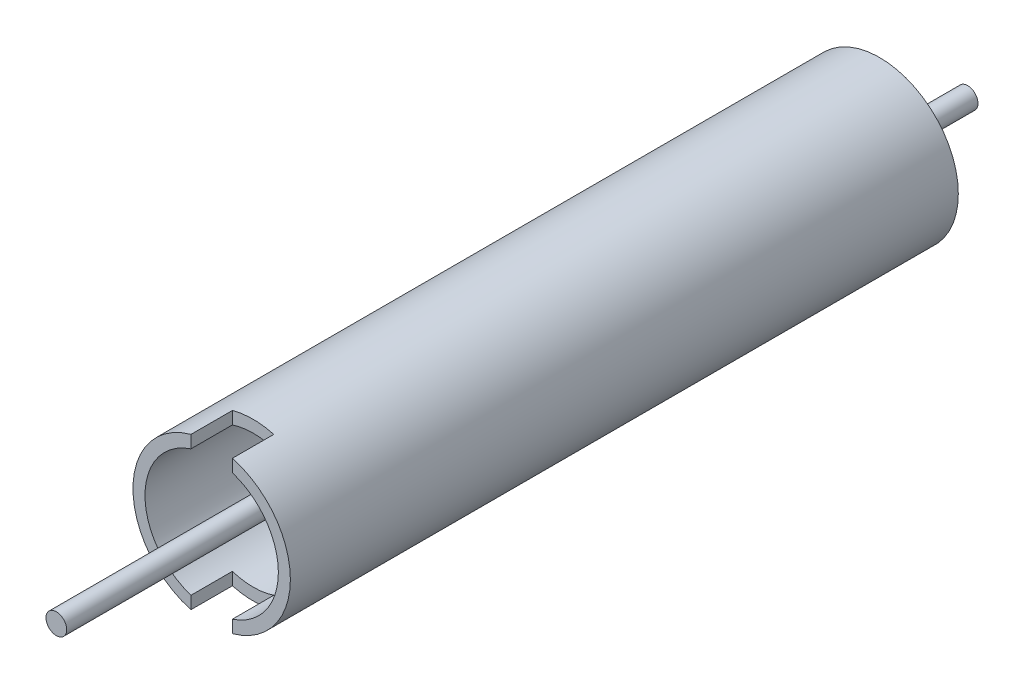
from build123d import *

# Parameters (mm, degrees)
SKETCH1_R                = 3.175
BOSS_EXTRUDE1_DEPTH      = 139.7
SKETCH2_R                = 24.13
SKETCH2_R_2              = 20.447
BOSS_EXTRUDE2_DEPTH      = 92.075
BOSS_EXTRUDE2_DEPTH_BACK = 112.7125
CUT_EXTRUDE1_START       = 19.43598
SKETCH3_W                = 12.7
SKETCH3_H                = 12.7
CUT_EXTRUDE1_DEPTH       = 4.69402


with BuildPart() as part:
    # Sketch1 → Boss-Extrude1 (new body, symmetric)
    with BuildSketch(Plane.XY):
        Circle(SKETCH1_R)
    extrude(amount=BOSS_EXTRUDE1_DEPTH, both=True)


with BuildPart() as body_2:
    # Sketch2 → Boss-Extrude2 (new body, two sides)
    with BuildSketch(Plane.XY) as boss_extrude2_sk:
        Circle(SKETCH2_R)
        Circle(SKETCH2_R_2, mode=Mode.SUBTRACT)
    extrude(amount=BOSS_EXTRUDE2_DEPTH)
    extrude(boss_extrude2_sk.sketch, amount=-BOSS_EXTRUDE2_DEPTH_BACK)

    # Sketch3 → Cut-Extrude1 (cut)
    with BuildSketch(Plane(origin=(0, 0, 0), x_dir=(1, 0, 0), z_dir=(0, 1, 0)).offset(CUT_EXTRUDE1_START)):
        with Locations((0, -85.725)):
            Rectangle(SKETCH3_W, SKETCH3_H)
    cut_extrude1 = extrude(amount=CUT_EXTRUDE1_DEPTH, mode=Mode.SUBTRACT)

    # Mirror1: Cut-Extrude1 across plane
    add(cut_extrude1.mirror(Plane.ZX), mode=Mode.SUBTRACT)


solid = Compound([part.part, body_2.part])
